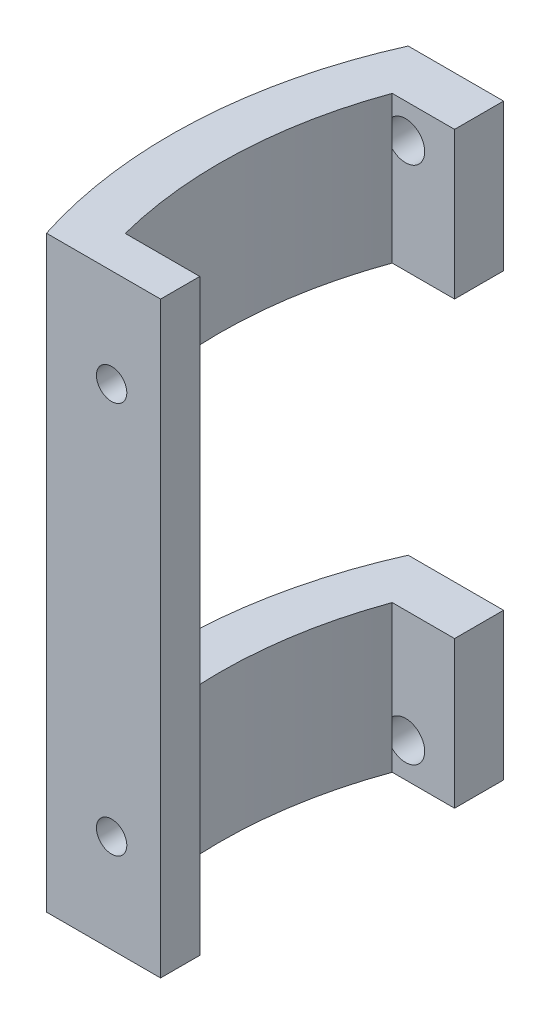
from build123d import *

# Parameters (mm, degrees)
BOSS_EXTRUDE1_DEPTH = 60
SKETCH2_R           = 1.55
CUT_EXTRUDE1_DEPTH  = 5
SKETCH3_R           = 1.95
CUT_EXTRUDE2_DEPTH  = 5
SKETCH4_W           = 31
SKETCH4_H           = 30
CUT_EXTRUDE3_DEPTH  = 15


with BuildPart() as part:
    # Sketch1 → Boss-Extrude1 (new body)
    with BuildSketch(Plane(origin=(0, 0, 0), x_dir=(1, 0, 0), z_dir=(0, 1, 0))):
        with BuildLine():
            ThreePointArc((-44.732538493, 20), (-48.92681392, 2.677102848), (-46.647615159, -15))
            Line((-46.647615159, -15), (-41.36423576, -15))
            Line((-41.36423576, -15), (-35, -15))
            Line((-35, -15), (-35, -11))
            Line((-35, -11), (-42.602816808, -11))
            ThreePointArc((-42.602816808, -11), (-43.950159036, 2.093685925), (-41.36423576, 15))
            Line((-41.36423576, 15), (-35, 15))
            Line((-35, 15), (-35, 20))
            Line((-35, 20), (-39.191835885, 20))
            Line((-39.191835885, 20), (-44.732538493, 20))
        make_face()
    extrude(amount=BOSS_EXTRUDE1_DEPTH)

    # Sketch2 → Cut-Extrude1 (cut, through all)
    with BuildSketch(Plane(origin=(0, 0, 11), x_dir=(-1, 0, 0), z_dir=(0, 0, -1))):
        with Locations((39.997615159, 50)):
            Circle(SKETCH2_R)
        with Locations((39.997615159, 10)):
            Circle(SKETCH2_R)
    extrude(amount=-CUT_EXTRUDE1_DEPTH, mode=Mode.SUBTRACT)

    # Sketch3 → Cut-Extrude2 (cut)
    with BuildSketch(Plane(origin=(0, 0, -20), x_dir=(-1, 0, 0), z_dir=(0, 0, -1))):
        with Locations((40, 3.5)):
            Circle(SKETCH3_R)
        with Locations((40, 56.5)):
            Circle(SKETCH3_R)
    extrude(amount=-CUT_EXTRUDE2_DEPTH, mode=Mode.SUBTRACT)

    # Sketch4 → Cut-Extrude3 (cut, through all)
    with BuildSketch(Plane(origin=(-35, 0, 0), x_dir=(0, 0, -1), z_dir=(1, 0, 0))):
        with Locations((4.5, 30)):
            Rectangle(SKETCH4_W, SKETCH4_H)
    extrude(amount=-CUT_EXTRUDE3_DEPTH, mode=Mode.SUBTRACT)


solid = part.part
